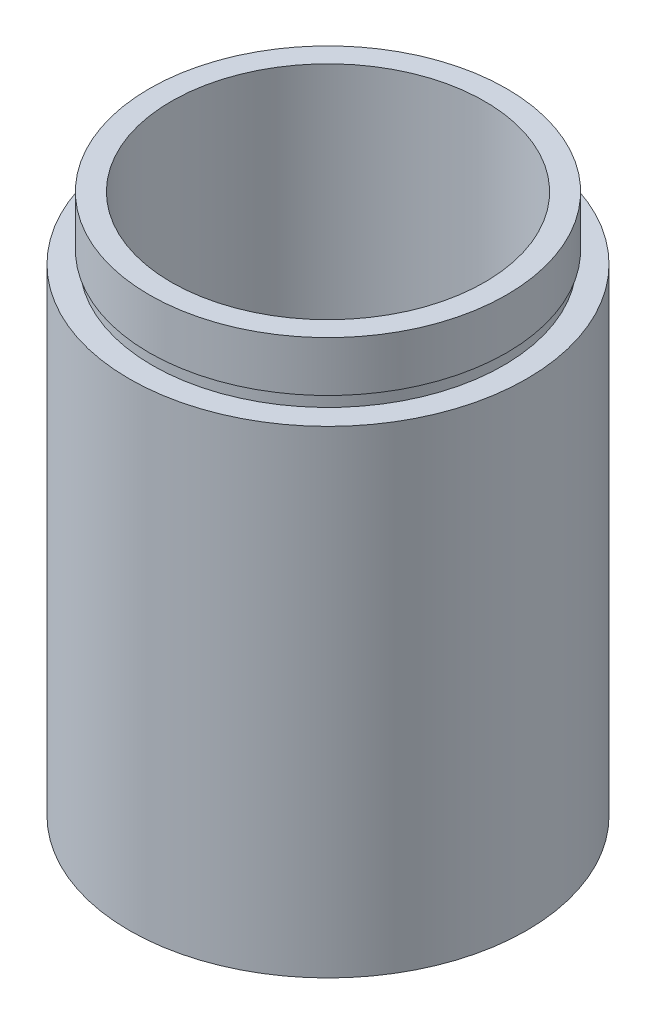
from build123d import *


with BuildPart() as part:
    # 草图1 → 旋转1 (revolve)
    with BuildSketch(Plane.XY, mode=Mode.PRIVATE) as revolve_1_sk:
        Polygon((14.25, 0), (14.25, 4.5), (14.35, 4.5), (14.35, 5.5), (12.5, 5.5), (12.5, 43.1), (14.25, 43.1), (14.25, 39.1), (14, 39.1), (14, 38.1), (15.85, 38.1), (15.85, 0), align=None)
    revolve(revolve_1_sk.sketch.rotate(Axis((0, 161.376166943, 0), (0, -1, 0)), 90), axis=Axis((0, 161.376166943, 0), (0, -1, 0)))  # turned: the seam where the file's is


solid = part.part
